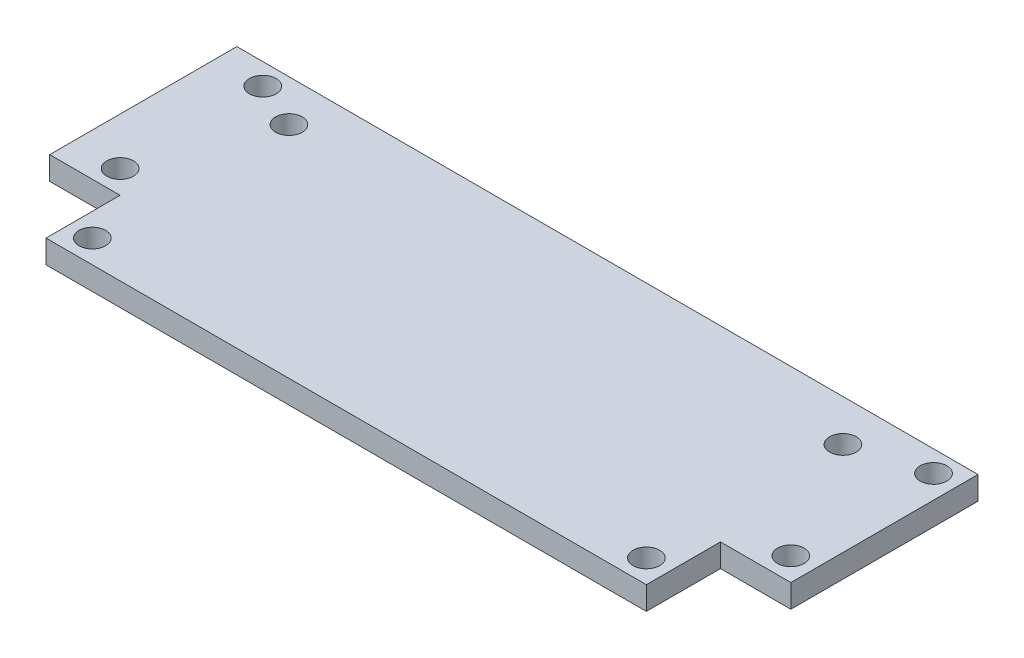
from build123d import *

# Parameters (mm, degrees)
SKETCH2_W           = 101.6
SKETCH2_H           = 35.814
BOSS_EXTRUDE1_DEPTH = 3.175
SKETCH3_R           = 1.8288
CUT_EXTRUDE1_DEPTH  = 4.175
SKETCH4_R           = 1.8288
CUT_EXTRUDE2_DEPTH  = 4.175
SKETCH5_W           = 9.651618186
SKETCH5_H           = 10.16
CUT_EXTRUDE3_DEPTH  = 4.175


with BuildPart() as part:
    # Sketch2 → Boss-Extrude1 (new body)
    with BuildSketch(Plane(origin=(0, 0, 0), x_dir=(1, 0, 0), z_dir=(0, 1, 0))):
        Rectangle(SKETCH2_W, SKETCH2_H)
    extrude(amount=BOSS_EXTRUDE1_DEPTH)

    # Sketch3 → Cut-Extrude1 (cut, through all)
    with BuildSketch(Plane(origin=(0, 3.175, 0), x_dir=(1, 0, 0), z_dir=(0, 1, 0))):
        with Locations((47.625, 14.986)):
            Circle(SKETCH3_R)
        with Locations((47.625, -4.572)):
            Circle(SKETCH3_R)
        with Locations((-44.323, 14.986)):
            Circle(SKETCH3_R)
        with Locations((-44.323, -4.572)):
            Circle(SKETCH3_R)
    extrude(amount=-CUT_EXTRUDE1_DEPTH, mode=Mode.SUBTRACT)

    # Sketch4 → Cut-Extrude2 (cut, through all)
    with BuildSketch(Plane(origin=(0, 3.175, 0), x_dir=(1, 0, 0), z_dir=(0, 1, 0))):
        with Locations((-37.973, -14.732)):
            Circle(SKETCH4_R)
        with Locations((-37.973, 12.2174)):
            Circle(SKETCH4_R)
        with Locations((37.973, -14.732)):
            Circle(SKETCH4_R)
        with Locations((37.973, 12.2174)):
            Circle(SKETCH4_R)
    extrude(amount=-CUT_EXTRUDE2_DEPTH, mode=Mode.SUBTRACT)

    # Sketch5 → Cut-Extrude3 (cut, through all)
    with BuildSketch(Plane(origin=(0, 3.175, 0), x_dir=(1, 0, 0), z_dir=(0, 1, 0))):
        with Locations((45.974190907, -12.827)):
            Rectangle(SKETCH5_W, SKETCH5_H)
        with Locations((-45.974190907, -12.827)):
            Rectangle(SKETCH5_W, SKETCH5_H)
    extrude(amount=-CUT_EXTRUDE3_DEPTH, mode=Mode.SUBTRACT)


solid = part.part
